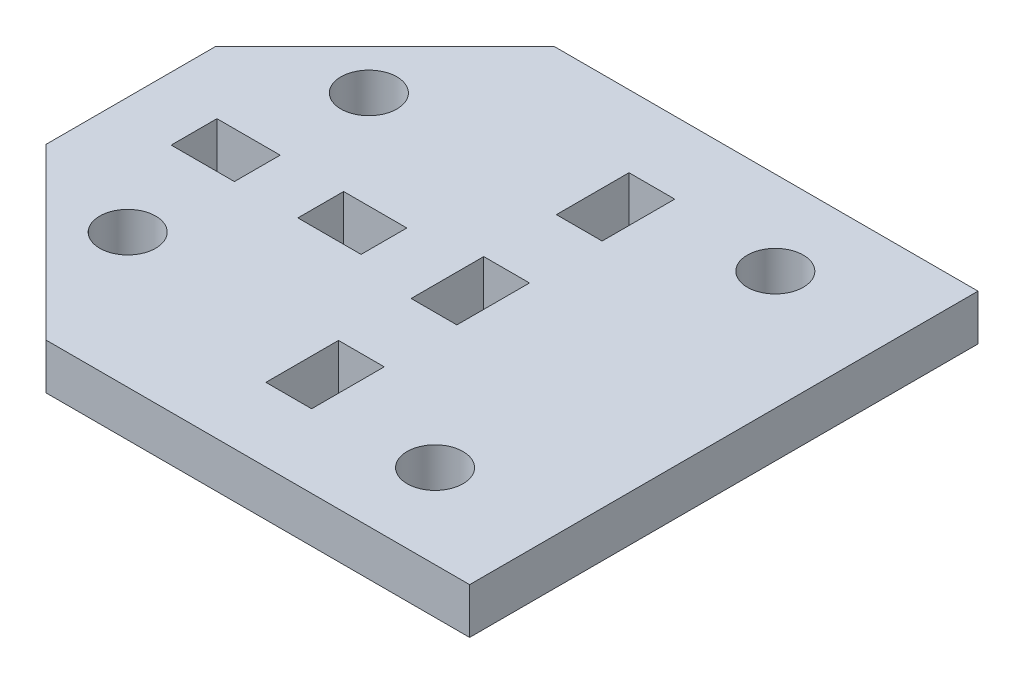
from build123d import *

# Parameters (mm, degrees)
SKETCH1_R           = 1.65
SKETCH1_W           = 2.7
SKETCH1_H           = 4.285714286
SKETCH1_H_2         = 4.285714285
SKETCH1_W_2         = 3.73
SKETCH1_H_3         = 2.7
BOSS_EXTRUDE1_DEPTH = 2.7


with BuildPart() as part:
    # Sketch1 → Boss-Extrude1 (new body)
    with BuildSketch(Plane(origin=(0, 0, 0), x_dir=(1, 0, 0), z_dir=(0, 1, 0))):
        Polygon((10.776704041, -15.946127132), (-9.223295959, -15.946127132), (-19.223295959, -5.946127132), (-19.223295959, 4.053872868), (-9.223295959, 14.053872868), (10.776704041, 14.053872868), (15.776704041, 14.053872868), (15.776704041, -15.946127132), align=None)
        with Locations((-12.32618077, -8.023001304)):
            Circle(SKETCH1_R, mode=Mode.SUBTRACT)
        with Locations((8.776704041, 9.093845285)):
            Circle(SKETCH1_R, mode=Mode.SUBTRACT)
        with Locations((-12.32618077, 6.210691875)):
            Circle(SKETCH1_R, mode=Mode.SUBTRACT)
        with Locations((8.776704041, -10.98609955)):
            Circle(SKETCH1_R, mode=Mode.SUBTRACT)
        with Locations((0.776704041, -9.477583286)):
            Rectangle(SKETCH1_W, SKETCH1_H, mode=Mode.SUBTRACT)
        with Locations((0.776704041, -0.906154715)):
            Rectangle(SKETCH1_W, SKETCH1_H, mode=Mode.SUBTRACT)
        with Locations((0.776704041, 7.665273857)):
            Rectangle(SKETCH1_W, SKETCH1_H_2, mode=Mode.SUBTRACT)
        with Locations((-13.628295959, -0.938132649)):
            Rectangle(SKETCH1_W_2, SKETCH1_H_3, mode=Mode.SUBTRACT)
        with Locations((-6.168295959, -0.922143682)):
            Rectangle(SKETCH1_W_2, SKETCH1_H_3, mode=Mode.SUBTRACT)
    extrude(amount=-BOSS_EXTRUDE1_DEPTH)


solid = part.part
